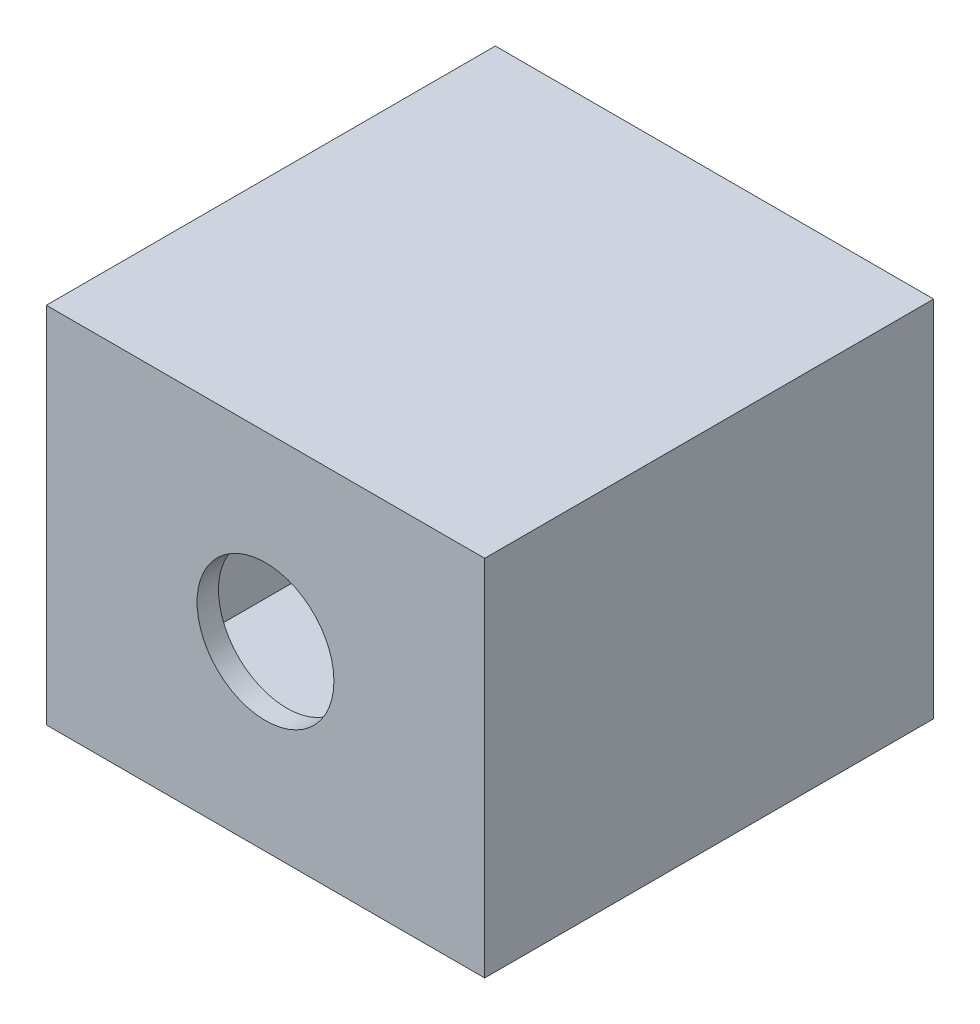
from build123d import *

# Parameters (mm, degrees)
CROQUIS1_W              = 20.5
CROQUIS1_H              = 17
CROQUIS1_W_2            = 18.5
CROQUIS1_H_2            = 15
SALIENTE_EXTRUIR1_DEPTH = 20
CROQUIS2_W              = 20.5
CROQUIS2_H              = 17
CROQUIS2_R              = 3.2
SALIENTE_EXTRUIR2_DEPTH = 1


with BuildPart() as part:
    # Croquis1 → Saliente-Extruir1 (new body)
    with BuildSketch(Plane.XY):
        with Locations((-39.801220416, 4.034561614)):
            Rectangle(CROQUIS1_W, CROQUIS1_H)
        with Locations((-39.801220416, 4.034561614)):
            Rectangle(CROQUIS1_W_2, CROQUIS1_H_2, mode=Mode.SUBTRACT)
    extrude(amount=SALIENTE_EXTRUIR1_DEPTH)

    # Croquis2 → Saliente-Extruir2 (add)
    with BuildSketch(Plane.XY.offset(20)):
        with Locations((-39.801220416, 4.034561614)):
            Rectangle(CROQUIS2_W, CROQUIS2_H)
        with Locations((-39.801220416, 4.034561614)):
            Circle(CROQUIS2_R, mode=Mode.SUBTRACT)
    extrude(amount=SALIENTE_EXTRUIR2_DEPTH)


solid = part.part
